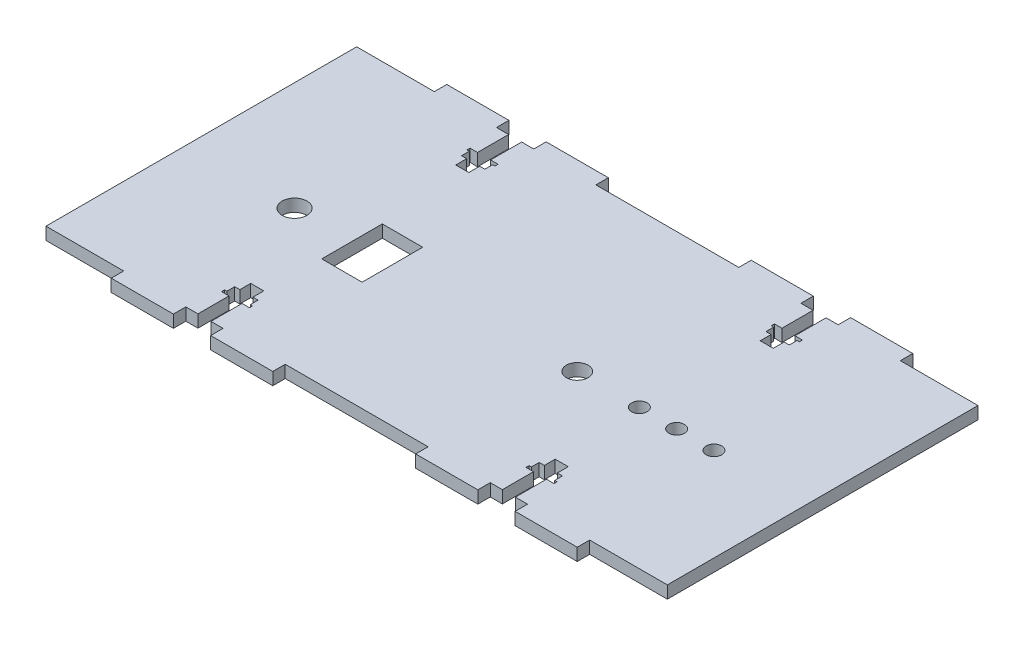
from build123d import *

# Parameters (mm, degrees)
BOSS_EXTRUDE1_DEPTH = 4
SKETCH2_R           = 4
SKETCH2_R_2         = 3.5
SKETCH2_R_3         = 2.5
SKETCH2_W           = 13
SKETCH2_H           = 19.5
CUT_EXTRUDE1_DEPTH  = 5
CUT_EXTRUDE2_DEPTH  = 6


with BuildPart() as part:
    # Sketch1 → Boss-Extrude1 (new body)
    with BuildSketch(Plane(origin=(0, 0, 0), x_dir=(1, 0, 0), z_dir=(0, 1, 0))):
        Polygon((-55, -50), (-43, -50), (-43, -54), (-23, -54), (-23, -50), (23, -50), (23, -54), (43, -54), (43, -50), (55, -50), (55, -54), (75, -54), (75, -50), (100, -50), (100, 50), (75, 50), (75, 54), (55, 54), (55, 50), (43, 50), (43, 54), (23, 54), (23, 50), (-23, 50), (-23, 54), (-43, 54), (-43, 50), (-55, 50), (-55, 54), (-75, 54), (-75, 50), (-100, 50), (-100, -50), (-75, -50), (-75, -54), (-55, -54), align=None)
    extrude(amount=BOSS_EXTRUDE1_DEPTH)

    # Sketch2 → Cut-Extrude1 (cut, through all)
    with BuildSketch(Plane.XZ):
        with Locations((-65, 5)):
            Circle(SKETCH2_R)
        with Locations((26, 5)):
            Circle(SKETCH2_R_2)
        with Locations((46, 5)):
            Circle(SKETCH2_R_3)
        with Locations((58, 5)):
            Circle(SKETCH2_R_3)
        with Locations((70, 5)):
            Circle(SKETCH2_R_3)
        with Locations((-40, 5)):
            Rectangle(SKETCH2_W, SKETCH2_H)
    extrude(amount=-CUT_EXTRUDE1_DEPTH, mode=Mode.SUBTRACT)

    # Sketch3 → Cut-Extrude2 (cut)
    with BuildSketch(Plane.XZ):
        Polygon((-51.1, -50), (-46.9, -50), (-46.9, -40), (-44.5, -40), (-44.5, -39), (-45.25, -39), (-45.25, -36.5), (-46.9, -36.5), (-46.9, -33), (-51.1, -33), (-51.1, -36.5), (-52.75, -36.5), (-52.75, -39), (-53.5, -39), (-53.5, -40), (-51.1, -40), align=None)
        Polygon((46.9, -50), (46.9, -40), (44.5, -40), (44.5, -39), (45.25, -39), (45.25, -36.5), (46.9, -36.5), (46.9, -33), (51.1, -33), (51.1, -36.5), (52.75, -36.5), (52.75, -39), (53.5, -39), (53.5, -40), (51.1, -40), (51.1, -50), align=None)
    cut_extrude2 = extrude(amount=-CUT_EXTRUDE2_DEPTH, mode=Mode.SUBTRACT)

    # Mirror1: Cut-Extrude2 across plane
    add(cut_extrude2.mirror(Plane.XY), mode=Mode.SUBTRACT)


solid = part.part
